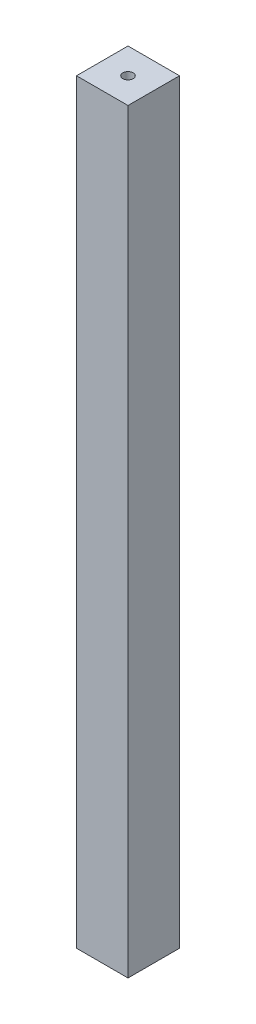
from build123d import *

# Parameters (mm, degrees)
SKETCH1_W           = 15
SKETCH1_H           = 15
SKETCH1_R           = 1.5
BOSS_EXTRUDE1_DEPTH = 220


with BuildPart() as part:
    # Sketch1 → Boss-Extrude1 (new body)
    with BuildSketch(Plane(origin=(0, 0, 0), x_dir=(1, 0, 0), z_dir=(0, 1, 0))):
        Rectangle(SKETCH1_W, SKETCH1_H)
        Circle(SKETCH1_R, mode=Mode.SUBTRACT)
    extrude(amount=BOSS_EXTRUDE1_DEPTH)


solid = part.part
